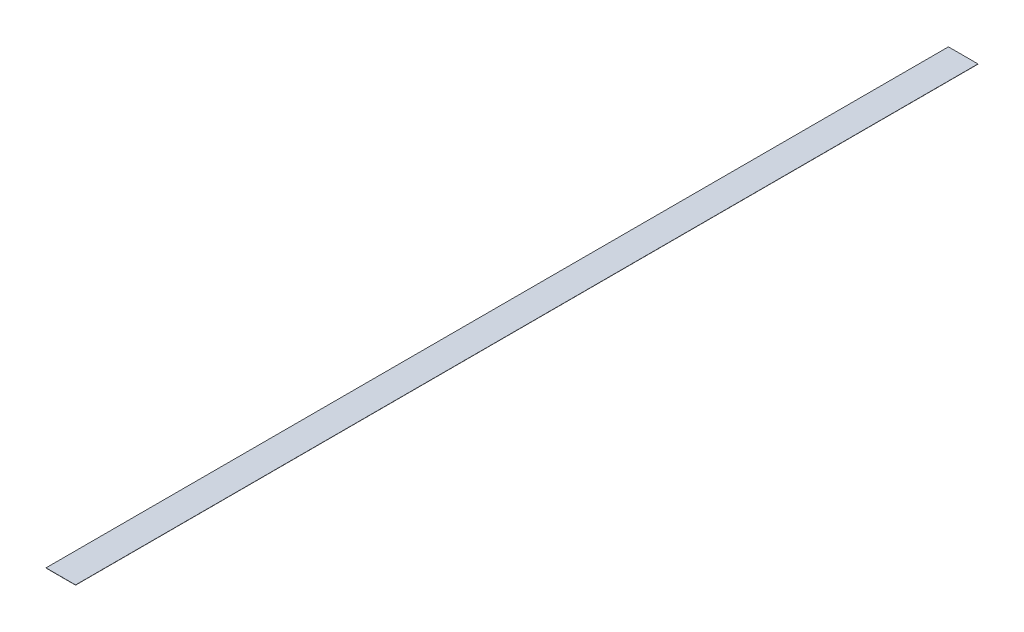
from build123d import *

# Parameters (mm, degrees)
SKETCH1_W           = 15
SKETCH1_H           = 457.6
BOSS_EXTRUDE1_DEPTH = 0.1


with BuildPart() as part:
    # Sketch1 → Boss-Extrude1 (new body)
    with BuildSketch(Plane(origin=(0, 0, 0), x_dir=(1, 0, 0), z_dir=(0, 1, 0))):
        with Locations((7.5, -228.8)):
            Rectangle(SKETCH1_W, SKETCH1_H)
    extrude(amount=BOSS_EXTRUDE1_DEPTH)


solid = part.part
